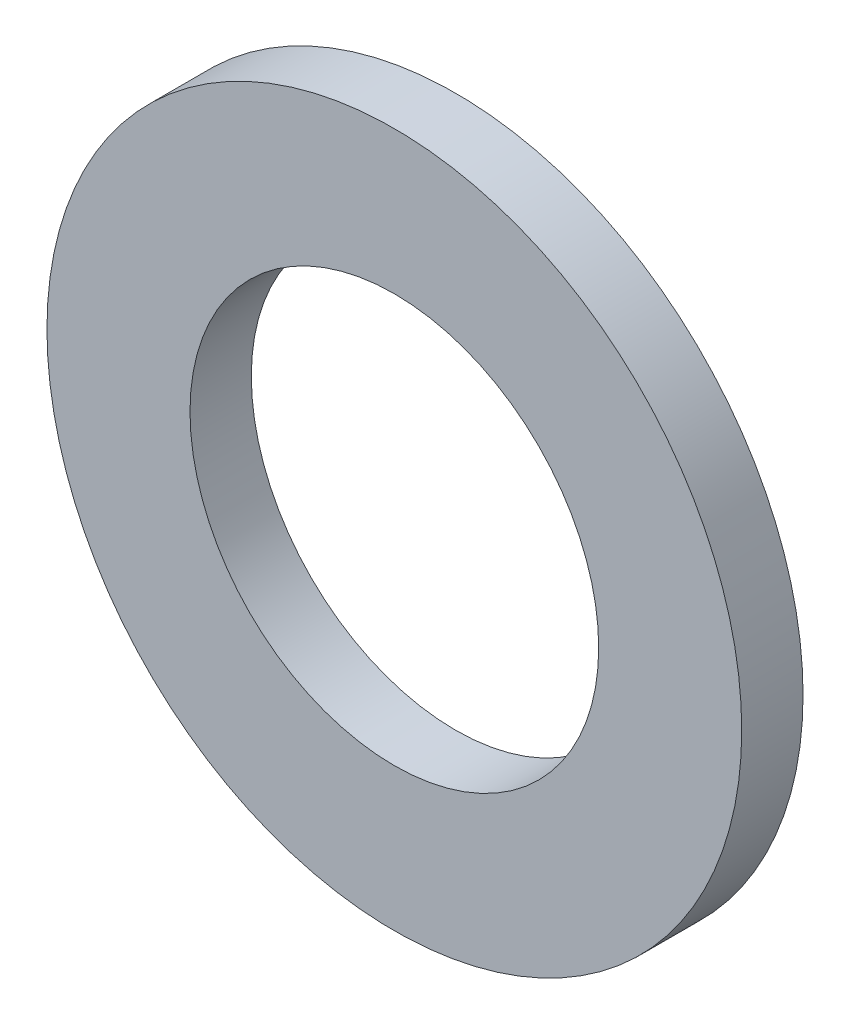
from build123d import *

# Parameters (mm, degrees)
SKETCH1_R           = 8.5
SKETCH1_R_2         = 5
BOSS_EXTRUDE1_DEPTH = 1.5


with BuildPart() as part:
    # Sketch1 → Boss-Extrude1 (new body)
    with BuildSketch(Plane.XY):
        Circle(SKETCH1_R)
        Circle(SKETCH1_R_2, mode=Mode.SUBTRACT)
    extrude(amount=BOSS_EXTRUDE1_DEPTH)


solid = part.part
